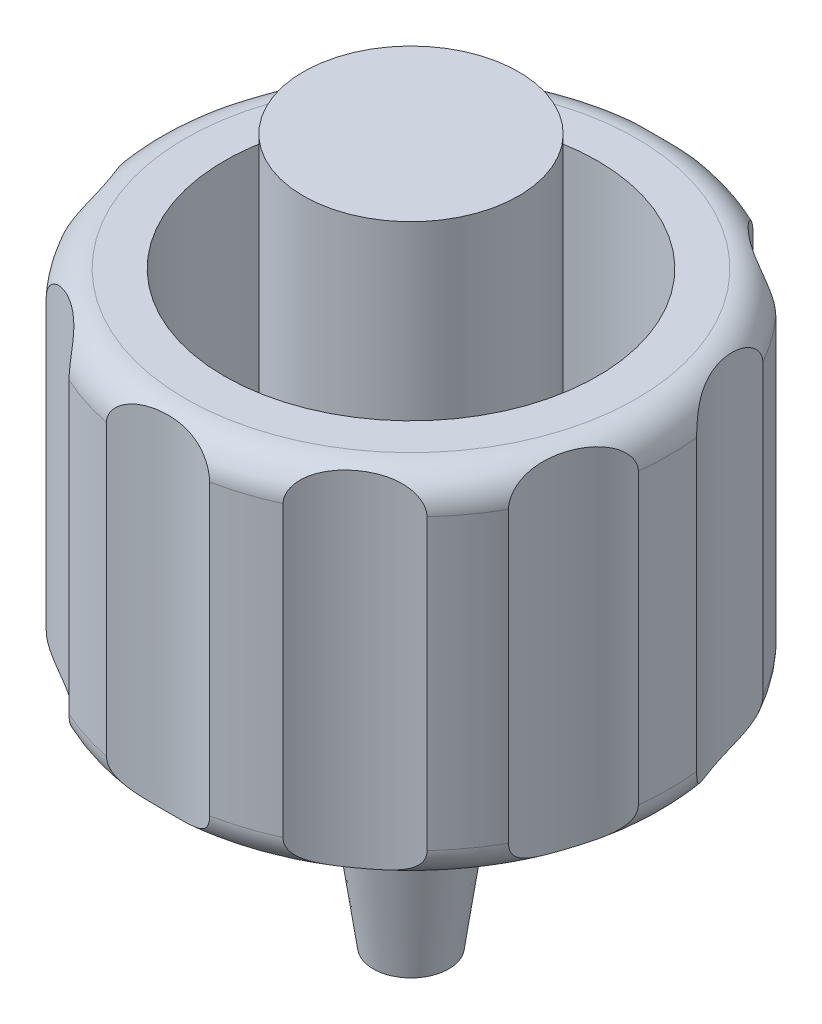
from build123d import *

# Parameters (mm, degrees)
SKETCH1_R           = 5.535
BOSS_EXTRUDE1_DEPTH = 7.6
FILLET1_R           = 0.7
SKETCH2_R           = 3
CUT_EXTRUDE1_DEPTH  = 7.6
CIRPATTERN1_COUNT   = 10
SKETCH4_R           = 4
CUT_EXTRUDE2_DEPTH  = 6.4
SKETCH5_R           = 2.307777858
BOSS_EXTRUDE2_DEPTH = 8.9


with BuildPart() as part:
    # Sketch1 → Boss-Extrude1 (new body)
    with BuildSketch(Plane(origin=(0, 0, 0), x_dir=(1, 0, 0), z_dir=(0, 1, 0))):
        Circle(SKETCH1_R)
    extrude(amount=BOSS_EXTRUDE1_DEPTH)

    # Fillet1
    fillet1_edges = [part.edges().sort_by_distance(p)[0] for p in [
        (-5.535, 0, 0),
        (-5.535, 7.6, 0),
    ]]
    fillet(fillet1_edges, radius=FILLET1_R)

    # Sketch2 → Cut-Extrude1 (cut)
    with BuildSketch(Plane(origin=(0, 0, 0), x_dir=(-1, 0, 0), z_dir=(0, -1, 0))):
        with Locations((0, 8.212488156)):
            Circle(SKETCH2_R)
    cut_extrude1 = extrude(amount=-CUT_EXTRUDE1_DEPTH, mode=Mode.SUBTRACT)

    # CirPattern1: Cut-Extrude1 ×10 about axis
    cirpattern1_axis = Axis((0, 0, 0), (0, 1, 0))
    for i in range(1, CIRPATTERN1_COUNT):
        add(cut_extrude1.rotate(cirpattern1_axis, i * 360 / CIRPATTERN1_COUNT), mode=Mode.SUBTRACT)

    # Sketch3 → Revolve1 (revolve)
    with BuildSketch(Plane.XY):
        Polygon((1.15, 0), (1, -1.2), (1, -2.58), (1.15, -2.58), (0.81, -5), (0, -5), (0, 0), align=None)
    revolve(axis=Axis((0, -5, 0), (0, 1, 0)))

    # Sketch4 → Cut-Extrude2 (cut)
    with BuildSketch(Plane(origin=(0, 7.6, 0), x_dir=(1, 0, 0), z_dir=(0, 1, 0))):
        Circle(SKETCH4_R)
    extrude(amount=-CUT_EXTRUDE2_DEPTH, mode=Mode.SUBTRACT)

    # Sketch5 → Boss-Extrude2 (add)
    with BuildSketch(Plane(origin=(0, 1.2, 0), x_dir=(1, 0, 0), z_dir=(0, 1, 0))):
        Circle(SKETCH5_R)
    extrude(amount=BOSS_EXTRUDE2_DEPTH)


solid = part.part
